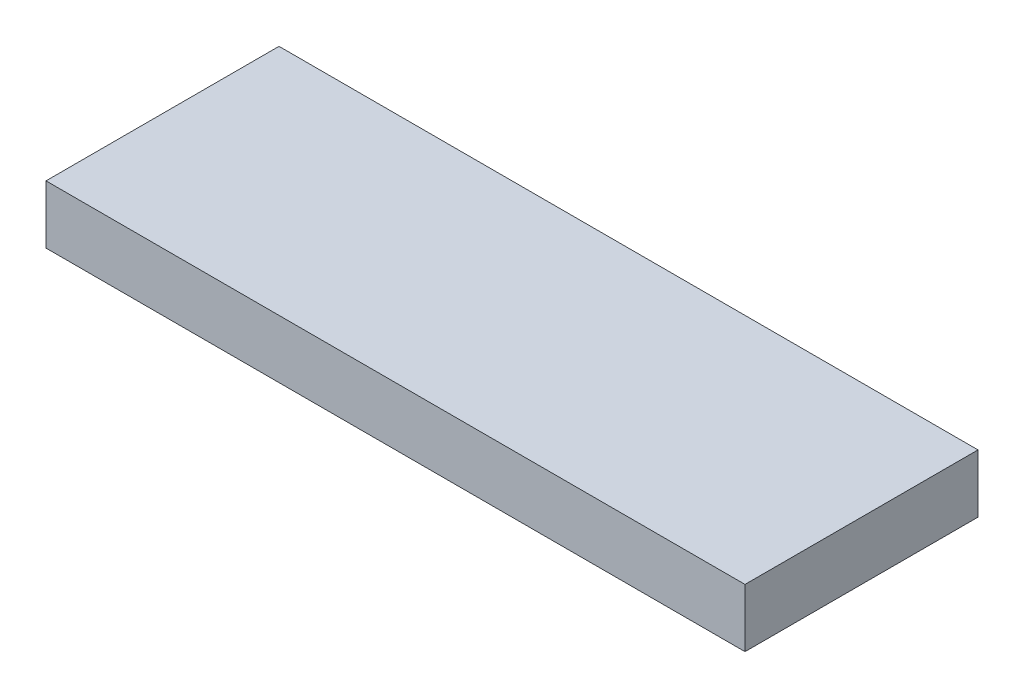
from build123d import *

# Parameters (mm, degrees)
SKETCH1_W           = 300
SKETCH1_H           = 100
BOSS_EXTRUDE1_DEPTH = 25


with BuildPart() as part:
    # Sketch1 → Boss-Extrude1 (new body)
    with BuildSketch(Plane(origin=(0, 0, 0), x_dir=(1, 0, 0), z_dir=(0, 1, 0))):
        Rectangle(SKETCH1_W, SKETCH1_H)
    extrude(amount=BOSS_EXTRUDE1_DEPTH)


solid = part.part
